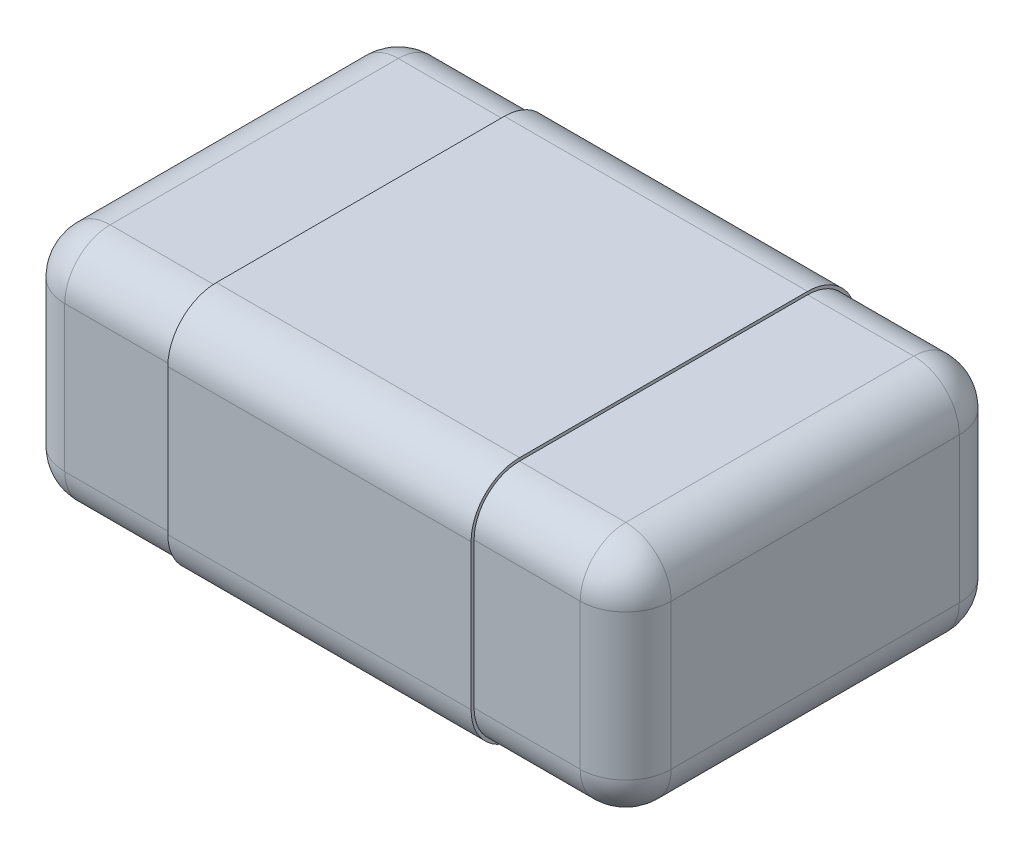
from build123d import *

# Parameters (mm, degrees)
ESBO_O1_W                     = 2
ESBO_O1_H                     = 1.25
RESSALTO_EXTRUS_O1_DEPTH      = 0.78
FILETE1_R                     = 0.15
RESSALTO_EXTRUS_O4_DEPTH      = 0.5
RESSALTO_EXTRUS_O4_DEPTH_BACK = 0.5
RESSALTO_EXTRUS_O5_DEPTH      = 0.02


with BuildPart() as part:
    # Esboço1 → Ressalto-extrusão1 (new body)
    with BuildSketch(Plane(origin=(0, 0, 0), x_dir=(1, 0, 0), z_dir=(0, 1, 0))):
        Rectangle(ESBO_O1_W, ESBO_O1_H)
    extrude(amount=-RESSALTO_EXTRUS_O1_DEPTH)

    # Filete1
    filete1_edges = [part.edges().sort_by_distance(p)[0] for p in [
        (1, -0.78, 0),
        (0, -0.78, -0.625),
        (-1, -0.78, 0),
        (0, 0, -0.625),
        (1, 0, 0),
        (0, 0, 0.625),
        (-1, 0, 0),
        (0, -0.78, 0.625),
        (-1, -0.39, -0.625),
        (1, -0.39, -0.625),
        (1, -0.39, 0.625),
        (-1, -0.39, 0.625),
    ]]
    fillet(filete1_edges, radius=FILETE1_R)

    # Esboço4 → Ressalto-extrusão4 (add, two sides)
    with BuildSketch(Plane(origin=(0, 0, 0), x_dir=(0, 0, -1), z_dir=(1, 0, 0))) as ressalto_extrus_o4_sk:
        with BuildLine():
            Line((0.635, -0.63), (0.635, -0.15))
            ThreePointArc((0.635, -0.15), (0.588137085, -0.036862915), (0.475, 0.01))
            Line((0.475, 0.01), (-0.475, 0.01))
            ThreePointArc((-0.475, 0.01), (-0.588137085, -0.036862915), (-0.635, -0.15))
            Line((-0.635, -0.15), (-0.635, -0.63))
            ThreePointArc((-0.635, -0.63), (-0.588137085, -0.743137085), (-0.475, -0.79))
            Line((-0.475, -0.79), (0.475, -0.79))
            ThreePointArc((0.475, -0.79), (0.588137085, -0.743137085), (0.635, -0.63))
        make_face()
        with BuildLine():
            Line((0.625, -0.63), (0.625, -0.15))
            ThreePointArc((0.625, -0.15), (0.581066017, -0.043933983), (0.475, 0))
            Line((0.475, 0), (-0.475, 0))
            ThreePointArc((-0.475, 0), (-0.581066017, -0.043933983), (-0.625, -0.15))
            Line((-0.625, -0.15), (-0.625, -0.63))
            ThreePointArc((-0.625, -0.63), (-0.581066017, -0.736066017), (-0.475, -0.78))
            Line((-0.475, -0.78), (0.475, -0.78))
            ThreePointArc((0.475, -0.78), (0.581066017, -0.736066017), (0.625, -0.63))
        make_face(mode=Mode.SUBTRACT)
    extrude(amount=RESSALTO_EXTRUS_O4_DEPTH)
    extrude(ressalto_extrus_o4_sk.sketch, amount=-RESSALTO_EXTRUS_O4_DEPTH_BACK)

    # Esboço2 → Ressalto-extrusão5 (add)
    with BuildSketch(Plane(origin=(0, -0.79, 0), x_dir=(0, 0, 1), z_dir=(0, -1, 0))):
        with BuildLine():
            add(Edge.make_bspline(
                [(0.10156651, -0.208860759), (0.106879767, -0.208966614), (0.117339076, -0.209174993), (0.132732901, -0.211067285), (0.147595912, -0.213803794), (0.161733203, -0.218074278), (0.175247857, -0.223104126), (0.187765566, -0.229473852), (0.199456364, -0.236780735), (0.206390579, -0.242629051), (0.209853694, -0.245549842)],
                knots=[0, 0, 0, 0, 1.090749778, 2.147174242, 3.181500652, 4.190524645, 5.176272442, 6.139085895, 7.070614365, 8, 8, 8, 8], degree=3))
            add(Edge.make_bspline(
                [(0.209853694, -0.245549842), (0.21311905, -0.248648627), (0.219631831, -0.254829179), (0.228217986, -0.265315666), (0.235504227, -0.276906839), (0.241897611, -0.289364979), (0.246965872, -0.302854946), (0.250464789, -0.317302021), (0.252731878, -0.332635304), (0.252955078, -0.343181184), (0.253069675, -0.348595728)],
                knots=[0, 0, 0, 0, 0.936773621, 1.868402867, 2.812865456, 3.782922538, 4.779926453, 5.805444567, 6.873255087, 8, 8, 8, 8], degree=3))
            add(Edge.make_bspline(
                [(0.253069675, -0.348595728), (0.252954756, -0.354339207), (0.252731949, -0.365474785), (0.250494446, -0.381642598), (0.246897537, -0.396750095), (0.241711627, -0.41070826), (0.235397547, -0.423499389), (0.227989531, -0.435087699), (0.219656812, -0.44561204), (0.213104073, -0.451559402), (0.209853694, -0.454509494)],
                knots=[0, 0, 0, 0, 1.166767194, 2.262152815, 3.310312399, 4.317229814, 5.282073077, 6.203969335, 7.109108255, 8, 8, 8, 8], degree=3))
            add(Edge.make_bspline(
                [(0.209853694, -0.454509494), (0.206450197, -0.457196472), (0.199608489, -0.462597834), (0.18818415, -0.469259267), (0.176017937, -0.475072744), (0.162950677, -0.479549924), (0.149297072, -0.482941808), (0.135240375, -0.48557209), (0.120750896, -0.487056172), (0.110964504, -0.487245866), (0.106016669, -0.487341772)],
                knots=[0, 0, 0, 0, 0.935651317, 1.880845668, 2.849172241, 3.844532839, 4.858290914, 5.886229154, 6.931312905, 8, 8, 8, 8], degree=3))
            add(Edge.make_bspline(
                [(0.106016669, -0.487341772), (0.099116071, -0.487130849), (0.085835493, -0.486724917), (0.066767801, -0.483694055), (0.049526906, -0.47846458), (0.033973962, -0.471159882), (0.020089772, -0.461670912), (0.007488682, -0.450389649), (-0.004090117, -0.43734813), (-0.010474264, -0.427440666), (-0.013742034, -0.422369462)],
                knots=[0, 0, 0, 0, 1.155460097, 2.223746009, 3.222673704, 4.163574145, 5.089979746, 6.028496165, 6.990872086, 8, 8, 8, 8], degree=3))
            Line((-0.013742034, -0.422369462), (-0.015818775, -0.422369462))
            add(Edge.make_bspline(
                [(-0.015818775, -0.422369462), (-0.019487518, -0.426963377), (-0.026656376, -0.435940054), (-0.039307386, -0.447320798), (-0.053073973, -0.456567943), (-0.068057105, -0.463459718), (-0.083987182, -0.468447164), (-0.100697057, -0.472100641), (-0.118342756, -0.474333407), (-0.130395462, -0.47456498), (-0.136566401, -0.474683544)],
                knots=[0, 0, 0, 0, 1.028847228, 2.010405056, 2.968496506, 3.92470531, 4.889287898, 5.888668269, 6.919006392, 8, 8, 8, 8], degree=3))
            add(Edge.make_bspline(
                [(-0.136566401, -0.474683544), (-0.141122544, -0.474614769), (-0.150102575, -0.474479214), (-0.163333834, -0.472613083), (-0.176222372, -0.470202453), (-0.18858602, -0.466327908), (-0.20052938, -0.461700457), (-0.211668091, -0.455615235), (-0.222429111, -0.448898386), (-0.228862529, -0.443418948), (-0.232096464, -0.440664557)],
                knots=[0, 0, 0, 0, 1.053534326, 2.07648671, 3.087937488, 4.084693284, 5.07073428, 6.046837634, 7.018188738, 8, 8, 8, 8], degree=3))
            add(Edge.make_bspline(
                [(-0.232096464, -0.440664557), (-0.235033406, -0.437895068), (-0.240992408, -0.432275824), (-0.248734939, -0.422529881), (-0.255613547, -0.411751512), (-0.261507163, -0.399991226), (-0.26644512, -0.387355948), (-0.269708194, -0.373777924), (-0.271878422, -0.359510856), (-0.272122449, -0.349724901), (-0.272246781, -0.344738924)],
                knots=[0, 0, 0, 0, 0.903175367, 1.832526527, 2.778734086, 3.7626714, 4.774575425, 5.809567684, 6.883967541, 8, 8, 8, 8], degree=3))
            add(Edge.make_bspline(
                [(-0.272246781, -0.344738924), (-0.272151383, -0.339457917), (-0.271966489, -0.32922263), (-0.270017631, -0.314432912), (-0.267048808, -0.300679126), (-0.262604859, -0.288071638), (-0.257309749, -0.276456028), (-0.251023062, -0.265980087), (-0.244154146, -0.256424906), (-0.238792828, -0.25092835), (-0.236151053, -0.248219937)],
                knots=[0, 0, 0, 0, 1.196021461, 2.318046731, 3.374579858, 4.378577803, 5.341149929, 6.262250503, 7.143728432, 8, 8, 8, 8], degree=3))
            add(Edge.make_bspline(
                [(-0.236151053, -0.248219937), (-0.233304845, -0.245647358), (-0.227572916, -0.240466486), (-0.217912552, -0.233878989), (-0.207433738, -0.228200548), (-0.196166483, -0.223481752), (-0.184188851, -0.219707606), (-0.171665328, -0.217093431), (-0.158664175, -0.215432945), (-0.149856128, -0.215271925), (-0.145367825, -0.215189873)],
                knots=[0, 0, 0, 0, 0.929209895, 1.871319939, 2.826088975, 3.814576506, 4.828105117, 5.865701633, 6.912428806, 8, 8, 8, 8], degree=3))
            add(Edge.make_bspline(
                [(-0.145367825, -0.215189873), (-0.139523445, -0.215390831), (-0.128096809, -0.215783733), (-0.111350344, -0.218549325), (-0.095583537, -0.223484275), (-0.0805949, -0.230082649), (-0.066657411, -0.238780562), (-0.053786771, -0.249424668), (-0.042207303, -0.262240711), (-0.035678553, -0.27193318), (-0.032333806, -0.276898734)],
                knots=[0, 0, 0, 0, 1.039845221, 2.033052711, 3.008945594, 3.972545647, 4.93935367, 5.922412001, 6.935629842, 8, 8, 8, 8], degree=3))
            Line((-0.032333806, -0.276898734), (-0.030355958, -0.276898734))
            add(Edge.make_bspline(
                [(-0.030355958, -0.276898734), (-0.026891269, -0.27134189), (-0.020098135, -0.260446718), (-0.007320301, -0.246365232), (0.006801666, -0.234377243), (0.022705907, -0.224894226), (0.040183962, -0.217665909), (0.059241428, -0.212600533), (0.079861724, -0.209317284), (0.09416922, -0.209016349), (0.10156651, -0.208860759)],
                knots=[0, 0, 0, 0, 1.004272695, 1.969053655, 2.907312273, 3.840967393, 4.801231943, 5.803715401, 6.864472521, 8, 8, 8, 8], degree=3))
        make_face()
        with BuildLine():
            add(Edge.make_bspline(
                [(-0.132215135, -0.297468354), (-0.136380522, -0.297607051), (-0.144357184, -0.297872653), (-0.155710072, -0.300247183), (-0.165760247, -0.304300455), (-0.174359999, -0.309992096), (-0.181409401, -0.316982423), (-0.18639881, -0.325426358), (-0.189458951, -0.335005481), (-0.189794798, -0.341814614), (-0.1899683, -0.345332278)],
                knots=[0, 0, 0, 0, 1.182217376, 2.263931421, 3.275960966, 4.242069709, 5.17568556, 6.070163463, 7.003027686, 8, 8, 8, 8], degree=3))
            add(Edge.make_bspline(
                [(-0.1899683, -0.345332278), (-0.189807673, -0.348680147), (-0.189495162, -0.35519363), (-0.186765296, -0.364457842), (-0.182196498, -0.372688355), (-0.175926912, -0.379715958), (-0.168300215, -0.385313756), (-0.159752876, -0.389426104), (-0.150395642, -0.392012357), (-0.14386849, -0.392271965), (-0.140522097, -0.392405063)],
                knots=[0, 0, 0, 0, 1.049890576, 2.042626796, 3.002028929, 3.984834553, 4.97676053, 5.953877561, 6.950977715, 8, 8, 8, 8], degree=3))
            add(Edge.make_bspline(
                [(-0.140522097, -0.392405063), (-0.137184919, -0.392325846), (-0.130836687, -0.392175151), (-0.121853582, -0.390626236), (-0.113810147, -0.388386658), (-0.106803441, -0.384740731), (-0.100394881, -0.380191481), (-0.094562106, -0.374438372), (-0.088668044, -0.36794172), (-0.08537079, -0.362888497), (-0.083658964, -0.360265032)],
                knots=[0, 0, 0, 0, 1.162060237, 2.210558868, 3.170354972, 4.05944165, 4.949122241, 5.900141539, 6.909823035, 8, 8, 8, 8], degree=3))
            add(Edge.make_bspline(
                [(-0.083658964, -0.360265032), (-0.082012351, -0.357646352), (-0.078512447, -0.352080304), (-0.07450678, -0.344503212), (-0.071066065, -0.337503692), (-0.067880233, -0.331349914), (-0.064452222, -0.324295514), (-0.06200498, -0.31935482), (-0.060715926, -0.316752373)],
                knots=[0, 0, 0, 0, 1.130971294, 2.403898383, 3.131735732, 3.983592061, 4.937882926, 6, 6, 6, 6], degree=3))
            add(Edge.make_bspline(
                [(-0.060715926, -0.316752373), (-0.06641069, -0.313690527), (-0.077319205, -0.307825457), (-0.091807652, -0.30276703), (-0.103354837, -0.299851572), (-0.112473982, -0.298576407), (-0.12214047, -0.297610842), (-0.128784071, -0.297516881), (-0.132215135, -0.297468354)],
                knots=[0, 0, 0, 0, 1.549968566, 2.969017665, 3.669516752, 4.405879138, 5.176721824, 6, 6, 6, 6], degree=3))
        make_face(mode=Mode.SUBTRACT)
        with BuildLine():
            add(Edge.make_bspline(
                [(0.108884548, -0.291139241), (0.104892524, -0.291228581), (0.097338883, -0.291397628), (0.086716555, -0.292782084), (0.077593058, -0.295395397), (0.069449939, -0.298903167), (0.062131212, -0.304490684), (0.054775961, -0.311979186), (0.047110721, -0.32175367), (0.042203605, -0.329237261), (0.039560972, -0.333267405)],
                knots=[0, 0, 0, 0, 1.110467001, 2.10120692, 2.969029817, 3.74460568, 4.551581512, 5.511195423, 6.65970232, 8, 8, 8, 8], degree=3))
            add(Edge.make_bspline(
                [(0.039560972, -0.333267405), (0.038735839, -0.334651212), (0.036934921, -0.337671479), (0.034047572, -0.342569534), (0.031006642, -0.348389595), (0.026545619, -0.356887997), (0.021202914, -0.367441755), (0.016673954, -0.37560565), (0.014541194, -0.379450158)],
                knots=[0, 0, 0, 0, 0.552049761, 1.204892215, 1.947677355, 2.801446134, 4.49374991, 6, 6, 6, 6], degree=3))
            add(Edge.make_bspline(
                [(0.014541194, -0.379450158), (0.016924719, -0.381101087), (0.021810016, -0.384484847), (0.02983363, -0.389035361), (0.038590124, -0.393345065), (0.048055111, -0.397414063), (0.058178612, -0.400969933), (0.068989041, -0.403217528), (0.080224882, -0.404805178), (0.087880495, -0.404976243), (0.091776162, -0.405063291)],
                knots=[0, 0, 0, 0, 0.84097559, 1.723672222, 2.673327577, 3.671825391, 4.712366938, 5.779946806, 6.870294663, 8, 8, 8, 8], degree=3))
            add(Edge.make_bspline(
                [(0.091776162, -0.405063291), (0.097495389, -0.40486813), (0.108436295, -0.404494785), (0.123933068, -0.401309642), (0.137697186, -0.396101078), (0.147575586, -0.389782828), (0.154410419, -0.383948152), (0.158812382, -0.379176351), (0.162447345, -0.373979921), (0.165588309, -0.368566756), (0.167831349, -0.362736718), (0.169521031, -0.356646626), (0.170685242, -0.350188995), (0.170755333, -0.345733107), (0.170791194, -0.343453323)],
                knots=[0, 0, 0, 0, 1.82868677, 3.498286175, 5.038063267, 6.513020263, 7.223581439, 7.910491715, 8.583738502, 9.249756143, 9.907958278, 10.575977979, 11.271421629, 12, 12, 12, 12], degree=3))
            add(Edge.make_bspline(
                [(0.170791194, -0.343453323), (0.170629135, -0.340764778), (0.170278642, -0.334950114), (0.167480803, -0.326202518), (0.163710247, -0.317041453), (0.159339027, -0.311911448), (0.157144042, -0.309335443)],
                knots=[0, 0, 0, 0, 0.858646439, 1.857042177, 2.923925168, 4, 4, 4, 4], degree=3))
            add(Edge.make_bspline(
                [(0.157144042, -0.309335443), (0.154335994, -0.306742767), (0.148657165, -0.301499496), (0.139976584, -0.296703691), (0.132147574, -0.293795496), (0.125230732, -0.292264447), (0.117386274, -0.291254492), (0.111822037, -0.291179062), (0.108884548, -0.291139241)],
                knots=[0, 0, 0, 0, 1.291292098, 2.611431705, 3.325135324, 4.116172842, 5.005484342, 6, 6, 6, 6], degree=3))
        make_face(mode=Mode.SUBTRACT)
        with BuildLine():
            Line((0.240411447, 0.120886076), (0.240411447, -0.125949367))
            Line((0.240411447, -0.125949367), (0.158330751, -0.125949367))
            add(Edge.make_bspline(
                [(0.158330751, -0.125949367), (0.152214367, -0.120887492), (0.140208237, -0.110951304), (0.12230397, -0.0966561), (0.104986645, -0.083034363), (0.088088852, -0.070297559), (0.071638652, -0.058342649), (0.055729879, -0.0469833), (0.04010761, -0.036552305), (0.02977976, -0.029910657), (0.024727112, -0.026661392)],
                knots=[0, 0, 0, 0, 1.143871494, 2.245357909, 3.300914739, 4.318253735, 5.293884102, 6.230829319, 7.13447631, 8, 8, 8, 8], degree=3))
            add(Edge.make_bspline(
                [(0.024727112, -0.026661392), (0.018467772, -0.022807477), (0.00649251, -0.01543423), (-0.011299949, -0.005831909), (-0.027841839, 0.002212488), (-0.043428254, 0.008711535), (-0.058501424, 0.013740093), (-0.073657737, 0.017037996), (-0.088968207, 0.019226969), (-0.099276497, 0.019489231), (-0.104426369, 0.019620253)],
                knots=[0, 0, 0, 0, 1.267768508, 2.425473269, 3.486024264, 4.439590646, 5.336903618, 6.222592004, 7.112032784, 8, 8, 8, 8], degree=3))
            add(Edge.make_bspline(
                [(-0.104426369, 0.019620253), (-0.109973533, 0.019457389), (-0.120442742, 0.019150014), (-0.135183808, 0.016680702), (-0.147862366, 0.012207249), (-0.158544157, 0.006120486), (-0.16699737, -0.001718213), (-0.172986786, -0.011118674), (-0.176714501, -0.021909536), (-0.177106684, -0.029597078), (-0.177310072, -0.033583861)],
                knots=[0, 0, 0, 0, 1.306909451, 2.466541577, 3.505869428, 4.459795217, 5.344572835, 6.193571478, 7.063180651, 8, 8, 8, 8], degree=3))
            add(Edge.make_bspline(
                [(-0.177310072, -0.033583861), (-0.177088445, -0.037797417), (-0.176649647, -0.046139784), (-0.172906717, -0.058228164), (-0.167362161, -0.069794193), (-0.162961227, -0.077292083), (-0.160696148, -0.081151108)],
                knots=[0, 0, 0, 0, 0.988472559, 1.957064427, 2.948539211, 4, 4, 4, 4], degree=3))
            add(Edge.make_bspline(
                [(-0.160696148, -0.081151108), (-0.158162705, -0.084765881), (-0.153335217, -0.091653849), (-0.14551733, -0.100442138), (-0.138585493, -0.107235065), (-0.134646389, -0.111371202), (-0.133006275, -0.113093354)],
                knots=[0, 0, 0, 0, 1.249878488, 2.381649198, 3.326171657, 4, 4, 4, 4], degree=3))
            Line((-0.133006275, -0.113093354), (-0.133006275, -0.119620253))
            Line((-0.133006275, -0.119620253), (-0.241293458, -0.119620253))
            add(Edge.make_bspline(
                [(-0.241293458, -0.119620253), (-0.243030602, -0.116915918), (-0.246833272, -0.110996035), (-0.251734635, -0.100573059), (-0.256834934, -0.088217246), (-0.26197876, -0.074279085), (-0.266458759, -0.059444232), (-0.269739252, -0.04443776), (-0.271805277, -0.029718517), (-0.272101339, -0.019975966), (-0.272246781, -0.015189873)],
                knots=[0, 0, 0, 0, 0.69970136, 1.531670699, 2.504079761, 3.612943238, 4.767349377, 5.877514774, 6.957315063, 8, 8, 8, 8], degree=3))
            add(Edge.make_bspline(
                [(-0.272246781, -0.015189873), (-0.272145838, -0.010272103), (-0.271949257, -0.000695027), (-0.270052265, 0.013195591), (-0.266883874, 0.026152524), (-0.262513205, 0.038190645), (-0.2570145, 0.049402474), (-0.24997581, 0.059529553), (-0.241814993, 0.068790356), (-0.232475839, 0.077159072), (-0.221906303, 0.084420345), (-0.21043315, 0.090921092), (-0.197820463, 0.096215142), (-0.184283525, 0.100709579), (-0.169658558, 0.103983447), (-0.154107163, 0.106468649), (-0.137518514, 0.107964222), (-0.126119876, 0.108138228), (-0.120249154, 0.108227848)],
                knots=[0, 0, 0, 0, 1.059873424, 2.064042983, 3.015596836, 3.930697506, 4.820695307, 5.699957467, 6.581199529, 7.477193696, 8.396013015, 9.341094634, 10.315416404, 11.340324501, 12.412707035, 13.542640562, 14.734368785, 16, 16, 16, 16], degree=3))
            add(Edge.make_bspline(
                [(-0.120249154, 0.108227848), (-0.112856677, 0.108059762), (-0.098089689, 0.107723999), (-0.076109458, 0.104913559), (-0.054324675, 0.100623497), (-0.032644635, 0.094266035), (-0.010659972, 0.085942561), (0.01194365, 0.075421379), (0.035218138, 0.062351564), (0.050657644, 0.052374248), (0.058647207, 0.047211234)],
                knots=[0, 0, 0, 0, 0.92383478, 1.845424201, 2.765944236, 3.697111989, 4.666093288, 5.70224482, 6.810968485, 8, 8, 8, 8], degree=3))
            add(Edge.make_bspline(
                [(0.058647207, 0.047211234), (0.063540545, 0.043836713), (0.073096713, 0.037246632), (0.086879374, 0.027223149), (0.099855338, 0.017352653), (0.111778424, 0.007693196), (0.122497499, -0.001175041), (0.13166194, -0.008894608), (0.139184524, -0.015177183), (0.143567164, -0.018975648), (0.145474738, -0.020628956)],
                knots=[0, 0, 0, 0, 1.293836837, 2.526725554, 3.709287413, 4.842241028, 5.866627263, 6.737584004, 7.450524958, 8, 8, 8, 8], degree=3))
            Line((0.145474738, -0.020628956), (0.145474738, 0.120886076))
            Line((0.145474738, 0.120886076), (0.240411447, 0.120886076))
        make_face()
        with BuildLine():
            Line((0.240411447, 0.456962025), (0.240411447, 0.210126582))
            Line((0.240411447, 0.210126582), (0.158330751, 0.210126582))
            add(Edge.make_bspline(
                [(0.158330751, 0.210126582), (0.152214367, 0.215188458), (0.140208237, 0.225124645), (0.12230397, 0.239419849), (0.104986645, 0.253041586), (0.088088852, 0.26577839), (0.071638652, 0.277733301), (0.055729879, 0.289092649), (0.04010761, 0.299523645), (0.02977976, 0.306165292), (0.024727112, 0.309414557)],
                knots=[0, 0, 0, 0, 1.143871494, 2.245357909, 3.300914739, 4.318253735, 5.293884102, 6.230829319, 7.13447631, 8, 8, 8, 8], degree=3))
            add(Edge.make_bspline(
                [(0.024727112, 0.309414557), (0.018467772, 0.313268473), (0.00649251, 0.32064172), (-0.011299949, 0.33024404), (-0.027841839, 0.338288438), (-0.043428254, 0.344787485), (-0.058501424, 0.349816043), (-0.073657737, 0.353113945), (-0.088968207, 0.355302918), (-0.099276497, 0.35556518), (-0.104426369, 0.355696203)],
                knots=[0, 0, 0, 0, 1.267768508, 2.425473269, 3.486024264, 4.439590646, 5.336903618, 6.222592004, 7.112032784, 8, 8, 8, 8], degree=3))
            add(Edge.make_bspline(
                [(-0.104426369, 0.355696203), (-0.109973533, 0.355533338), (-0.120442742, 0.355225964), (-0.135183808, 0.352756651), (-0.147862366, 0.348283198), (-0.158544157, 0.342196435), (-0.16699737, 0.334357737), (-0.172986786, 0.324957276), (-0.176714501, 0.314166414), (-0.177106684, 0.306478871), (-0.177310072, 0.302492089)],
                knots=[0, 0, 0, 0, 1.306909451, 2.466541577, 3.505869428, 4.459795217, 5.344572835, 6.193571478, 7.063180651, 8, 8, 8, 8], degree=3))
            add(Edge.make_bspline(
                [(-0.177310072, 0.302492089), (-0.177088445, 0.298278533), (-0.176649647, 0.289936166), (-0.172906717, 0.277847785), (-0.167362161, 0.266281756), (-0.162961227, 0.258783866), (-0.160696148, 0.254924842)],
                knots=[0, 0, 0, 0, 0.988472559, 1.957064427, 2.948539211, 4, 4, 4, 4], degree=3))
            add(Edge.make_bspline(
                [(-0.160696148, 0.254924842), (-0.158162705, 0.251310068), (-0.153335217, 0.244422101), (-0.14551733, 0.235633811), (-0.138585493, 0.228840884), (-0.134646389, 0.224704747), (-0.133006275, 0.222982595)],
                knots=[0, 0, 0, 0, 1.249878488, 2.381649198, 3.326171657, 4, 4, 4, 4], degree=3))
            Line((-0.133006275, 0.222982595), (-0.133006275, 0.216455696))
            Line((-0.133006275, 0.216455696), (-0.241293458, 0.216455696))
            add(Edge.make_bspline(
                [(-0.241293458, 0.216455696), (-0.243030602, 0.219160031), (-0.246833272, 0.225079915), (-0.251734635, 0.23550289), (-0.256834934, 0.247858703), (-0.26197876, 0.261796864), (-0.266458759, 0.276631717), (-0.269739252, 0.29163819), (-0.271805277, 0.306357432), (-0.272101339, 0.316099983), (-0.272246781, 0.320886076)],
                knots=[0, 0, 0, 0, 0.69970136, 1.531670699, 2.504079761, 3.612943238, 4.767349377, 5.877514774, 6.957315063, 8, 8, 8, 8], degree=3))
            add(Edge.make_bspline(
                [(-0.272246781, 0.320886076), (-0.272145838, 0.325803846), (-0.271949257, 0.335380922), (-0.270052265, 0.349271541), (-0.266883874, 0.362228473), (-0.262513205, 0.374266594), (-0.2570145, 0.385478423), (-0.24997581, 0.395605503), (-0.241814993, 0.404866306), (-0.232475839, 0.413235021), (-0.221906303, 0.420496294), (-0.21043315, 0.426997042), (-0.197820463, 0.432291091), (-0.184283525, 0.436785528), (-0.169658558, 0.440059396), (-0.154107163, 0.442544598), (-0.137518514, 0.444040172), (-0.126119876, 0.444214178), (-0.120249154, 0.444303797)],
                knots=[0, 0, 0, 0, 1.059873424, 2.064042983, 3.015596836, 3.930697506, 4.820695307, 5.699957467, 6.581199529, 7.477193696, 8.396013015, 9.341094634, 10.315416404, 11.340324501, 12.412707035, 13.542640562, 14.734368785, 16, 16, 16, 16], degree=3))
            add(Edge.make_bspline(
                [(-0.120249154, 0.444303797), (-0.112856677, 0.444135712), (-0.098089689, 0.443799948), (-0.076109458, 0.440989509), (-0.054324675, 0.436699446), (-0.032644635, 0.430341984), (-0.010659972, 0.42201851), (0.01194365, 0.411497328), (0.035218138, 0.398427513), (0.050657644, 0.388450198), (0.058647207, 0.383287184)],
                knots=[0, 0, 0, 0, 0.92383478, 1.845424201, 2.765944236, 3.697111989, 4.666093288, 5.70224482, 6.810968485, 8, 8, 8, 8], degree=3))
            add(Edge.make_bspline(
                [(0.058647207, 0.383287184), (0.063540545, 0.379912662), (0.073096713, 0.373322582), (0.086879374, 0.363299098), (0.099855338, 0.353428602), (0.111778424, 0.343769145), (0.122497499, 0.334900909), (0.13166194, 0.327181341), (0.139184524, 0.320898767), (0.143567164, 0.317100301), (0.145474738, 0.315446994)],
                knots=[0, 0, 0, 0, 1.293836837, 2.526725554, 3.709287413, 4.842241028, 5.866627263, 6.737584004, 7.450524958, 8, 8, 8, 8], degree=3))
            Line((0.145474738, 0.315446994), (0.145474738, 0.456962025))
            Line((0.145474738, 0.456962025), (0.240411447, 0.456962025))
        make_face()
    extrude(amount=RESSALTO_EXTRUS_O5_DEPTH)


solid = part.part
